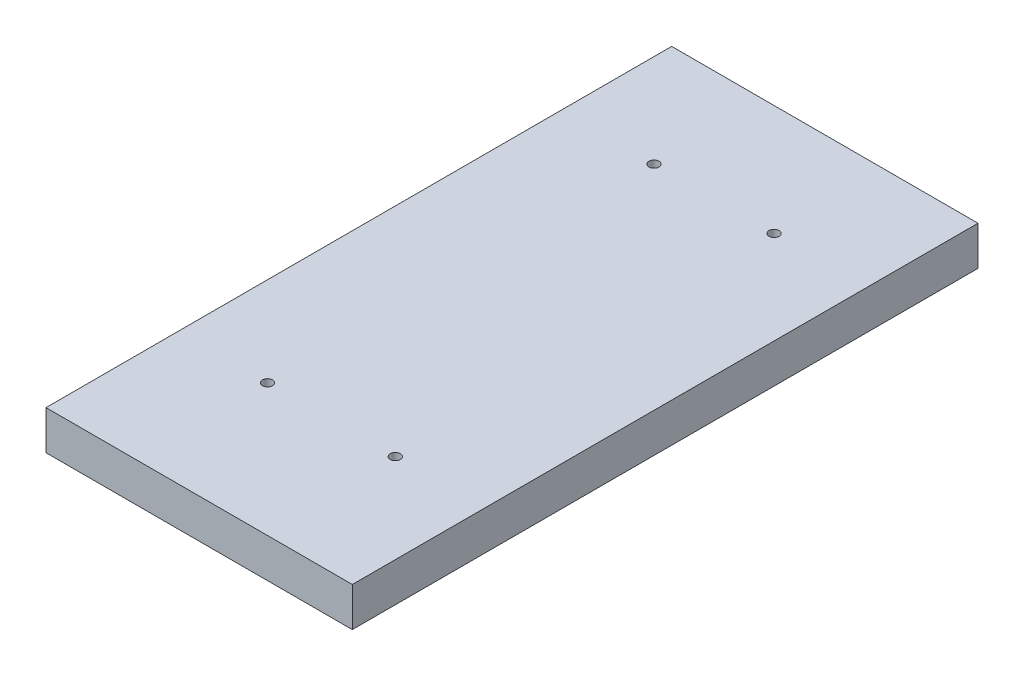
from build123d import *

# Parameters (mm, degrees)
SKETCH1_W             = 149.225
SKETCH1_H             = 304.8
BOSS_EXTRUDE1_DEPTH   = 19.05
F_8_CLEARANCE_HOLE1_D = 4.9149
F_8_CLEARANCE_HOLE2_D = 4.9149


with BuildPart() as part:
    # Sketch1 → Boss-Extrude1 (new body)
    with BuildSketch(Plane(origin=(0, 0, 0), x_dir=(1, 0, 0), z_dir=(0, 1, 0))):
        Rectangle(SKETCH1_W, SKETCH1_H)
    extrude(amount=BOSS_EXTRUDE1_DEPTH)

    # #8 Clearance Hole1 (through all)
    with Locations(Plane(origin=(0, 19.05, 0), x_dir=(1, 0, 0), z_dir=(0, 1, 0))):
        with Locations((-29.248151984, 98.425), (29.248151984, 98.425)):
            Hole(F_8_CLEARANCE_HOLE1_D / 2)

    # #8 Clearance Hole2 (through all)
    with Locations(Plane(origin=(0, 19.05, 0), x_dir=(1, 0, 0), z_dir=(0, 1, 0))):
        with Locations((-31.125, -87.9856), (31.125, -87.9856)):
            Hole(F_8_CLEARANCE_HOLE2_D / 2)


solid = part.part
